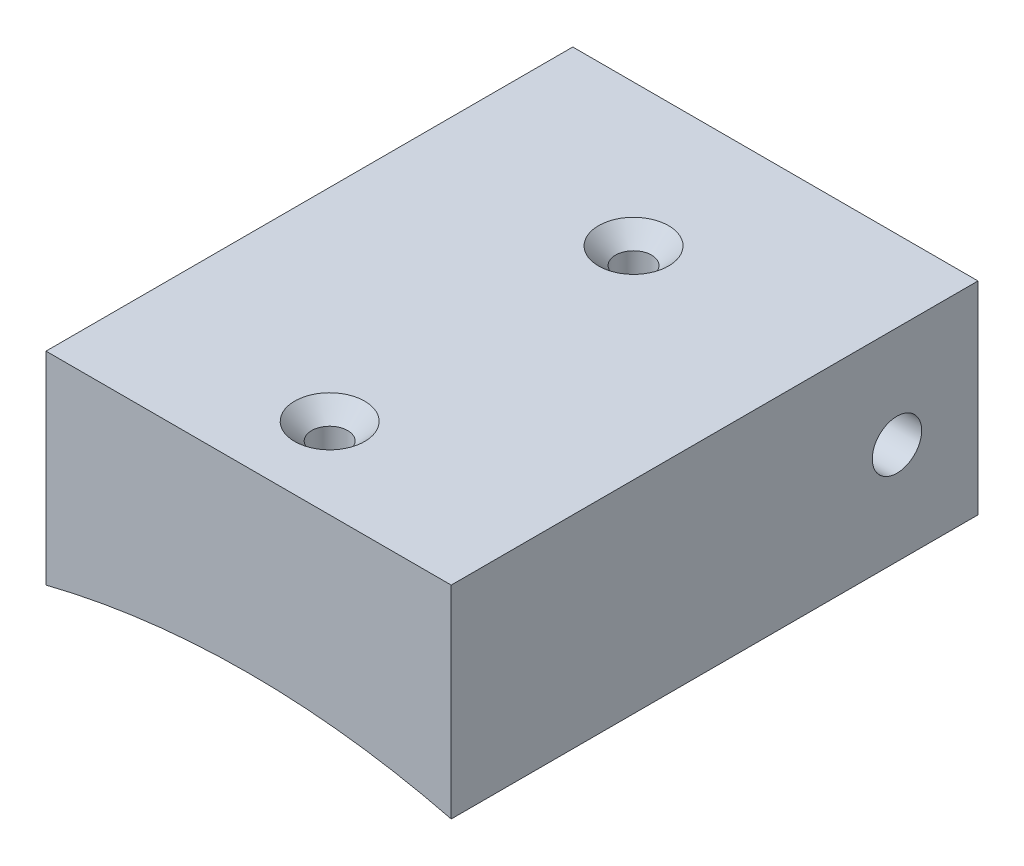
from build123d import *

# Parameters (mm, degrees)
BOSS_EXTRUDE1_DEPTH             = 11.5
F_2_56_TAPPED_HOLE3_D           = 1.778
F_2_56_TAPPED_HOLE3_CSINK_D     = 3.4544
F_2_56_TAPPED_HOLE3_CSINK_ANGLE = 90
BOSS_EXTRUDE2_DEPTH             = 3
F_2_CLEARANCE_HOLE1_D           = 2.4384


with BuildPart() as part:
    # Sketch1 → Boss-Extrude1 (new body, symmetric)
    with BuildSketch(Plane.XY):
        with BuildLine():
            Line((-10, 39.778288752), (-10, 49.778288752))
            Line((-10, 49.778288752), (10, 49.778288752))
            Line((10, 49.778288752), (10, 39.778288752))
            ThreePointArc((10, 39.778288752), (0, 41.016), (-10, 39.778288752))
        make_face()
    extrude(amount=BOSS_EXTRUDE1_DEPTH, both=True)

    # #2-56 Tapped Hole3 (through all)
    with Locations(Plane(origin=(0, 49.778288752, 0), x_dir=(1, 0, 0), z_dir=(0, 1, 0))):
        with Locations((0, -7.5), (0, 7.5)):
            CounterSinkHole(F_2_56_TAPPED_HOLE3_D / 2, F_2_56_TAPPED_HOLE3_CSINK_D / 2, counter_sink_angle=F_2_56_TAPPED_HOLE3_CSINK_ANGLE)

    # Sketch5 → Boss-Extrude2 (add)
    with BuildSketch(Plane(origin=(0, 0, -11.5), x_dir=(-1, 0, 0), z_dir=(0, 0, -1))):
        with BuildLine():
            Line((10, 49.778288752), (-10, 49.778288752))
            Line((-10, 49.778288752), (-10, 39.778288752))
            ThreePointArc((-10, 39.778288752), (0, 41.016), (10, 39.778288752))
            Line((10, 39.778288752), (10, 49.778288752))
        make_face()
    extrude(amount=BOSS_EXTRUDE2_DEPTH)

    # #2 Clearance Hole1 (through all)
    with Locations(Plane.ZY.offset(10)):
        with Locations((-10.5, 44.778288752)):
            Hole(F_2_CLEARANCE_HOLE1_D / 2)


solid = part.part
